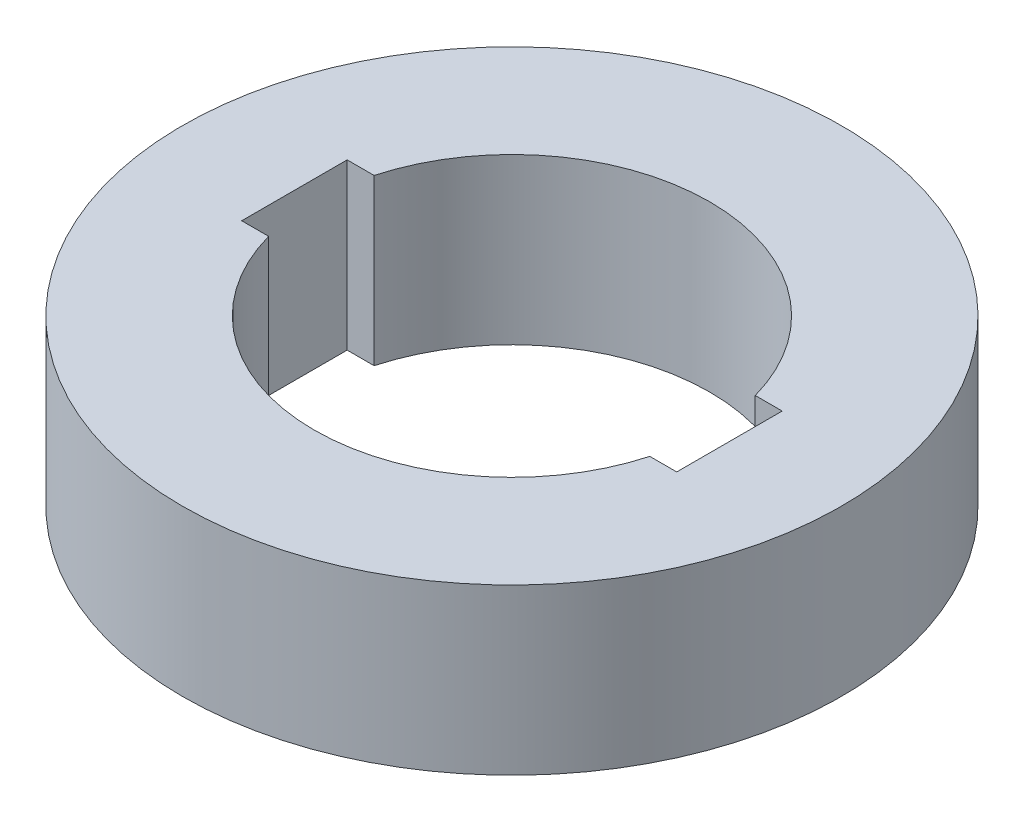
from build123d import *

# Parameters (mm, degrees)
SKETCH2_R           = 50
BOSS_EXTRUDE1_DEPTH = 25


with BuildPart() as part:
    # Sketch2 → Boss-Extrude1 (new body)
    with BuildSketch(Plane(origin=(0, 0, 0), x_dir=(1, 0, 0), z_dir=(0, 1, 0))):
        Circle(SKETCH2_R)
        with BuildLine():
            Line((28.91366459, 8), (33, 8))
            Line((33, 8), (33, -8))
            Line((33, -8), (28.91366459, -8))
            ThreePointArc((28.91366459, -8), (0, -30), (-28.91366459, -8))
            Line((-28.91366459, -8), (-33, -8))
            Line((-33, -8), (-33, 8))
            Line((-33, 8), (-28.91366459, 8))
            ThreePointArc((-28.91366459, 8), (0, 30), (28.91366459, 8))
        make_face(mode=Mode.SUBTRACT)
    extrude(amount=BOSS_EXTRUDE1_DEPTH)


solid = part.part
